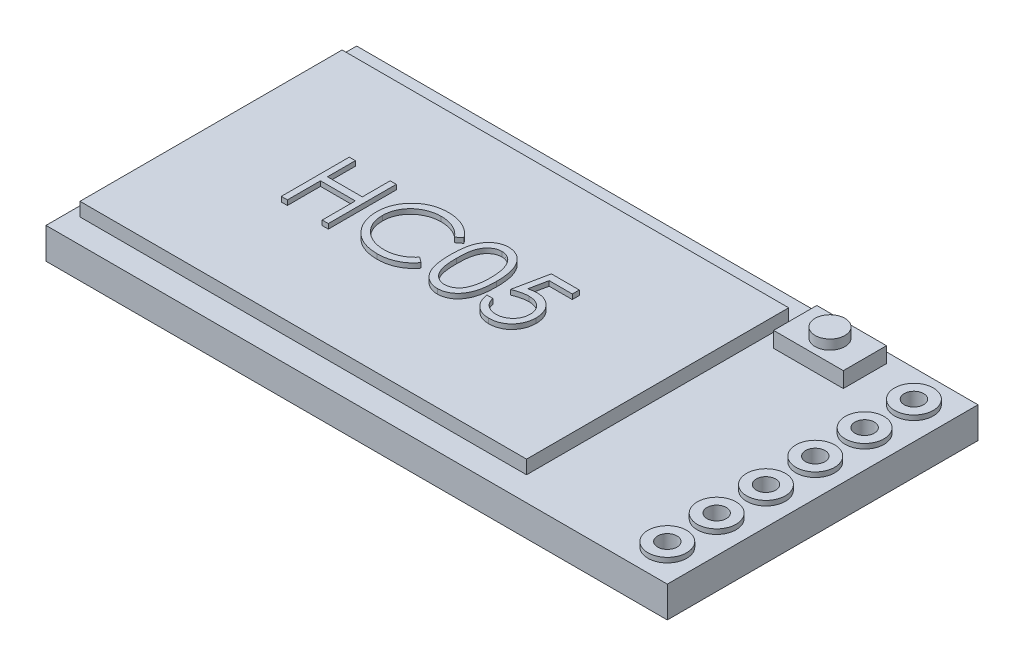
from build123d import *

# Parameters (mm, degrees)
SKETCH1_W           = 32
SKETCH1_H           = 16
SKETCH1_R           = 1
SKETCH1_W_2         = 23
SKETCH1_H_2         = 13.5
SKETCH1_W_3         = 3.590425902
SKETCH1_H_3         = 2.22474243
BOSS_EXTRUDE1_DEPTH = 1.6
SKETCH1_3_W         = 23
SKETCH1_3_H         = 13.5
BOSS_EXTRUDE2_DEPTH = 2.3
SKETCH1_4_W         = 3.590425902
SKETCH1_4_H         = 2.22474243
BOSS_EXTRUDE3_DEPTH = 2.4
SKETCH1_5_R         = 1
SKETCH1_5_R_2       = 0.5
BOSS_EXTRUDE4_DEPTH = 1.85
SKETCH2_R           = 0.766667283
BOSS_EXTRUDE5_DEPTH = 0.5
BOSS_EXTRUDE6_DEPTH = 0.25


with BuildPart() as part:
    # Sketch1 → Boss-Extrude1 (new body)
    with BuildSketch(Plane(origin=(0, 0, 0), x_dir=(1, 0, 0), z_dir=(0, 1, 0))):
        with Locations((16, 8)):
            Rectangle(SKETCH1_W, SKETCH1_H)
        with Locations((30.35, 1.65)):
            Circle(SKETCH1_R, mode=Mode.SUBTRACT)
        with Locations((30.35, 4.19)):
            Circle(SKETCH1_R, mode=Mode.SUBTRACT)
        with Locations((30.35, 6.73)):
            Circle(SKETCH1_R, mode=Mode.SUBTRACT)
        with Locations((12, 8)):
            Rectangle(SKETCH1_W_2, SKETCH1_H_2, mode=Mode.SUBTRACT)
        with Locations((30.35, 9.27)):
            Circle(SKETCH1_R, mode=Mode.SUBTRACT)
        with Locations((30.35, 11.81)):
            Circle(SKETCH1_R, mode=Mode.SUBTRACT)
        with Locations((26.014787049, 14.365507126)):
            Rectangle(SKETCH1_W_3, SKETCH1_H_3, mode=Mode.SUBTRACT)
        with Locations((30.35, 14.35)):
            Circle(SKETCH1_R, mode=Mode.SUBTRACT)
    extrude(amount=BOSS_EXTRUDE1_DEPTH)

    # Sketch1_3 → Boss-Extrude2 (add)
    with BuildSketch(Plane(origin=(0, 0, 0), x_dir=(1, 0, 0), z_dir=(0, 1, 0))):
        with Locations((12, 8)):
            Rectangle(SKETCH1_3_W, SKETCH1_3_H)
    extrude(amount=BOSS_EXTRUDE2_DEPTH)

    # Sketch1_4 → Boss-Extrude3 (add)
    with BuildSketch(Plane(origin=(0, 0, 0), x_dir=(1, 0, 0), z_dir=(0, 1, 0))):
        with Locations((26.014787049, 14.365507126)):
            Rectangle(SKETCH1_4_W, SKETCH1_4_H)
    extrude(amount=BOSS_EXTRUDE3_DEPTH)

    # Sketch1_5 → Boss-Extrude4 (add)
    # profile 1 of 6: a face of its own
    with BuildSketch(Plane(origin=(0, 0, 0), x_dir=(1, 0, 0), z_dir=(0, 1, 0))):
        with Locations((30.35, 14.35)):
            Circle(SKETCH1_5_R)
        with Locations((30.35, 14.35)):
            Circle(SKETCH1_5_R_2, mode=Mode.SUBTRACT)
    # profile 2 of 6: a face of its own
    with BuildSketch(Plane(origin=(0, 0, 0), x_dir=(1, 0, 0), z_dir=(0, 1, 0))):
        with Locations((30.35, 11.81)):
            Circle(SKETCH1_5_R)
        with Locations((30.35, 11.81)):
            Circle(SKETCH1_5_R_2, mode=Mode.SUBTRACT)
    # profile 3 of 6: a face of its own
    with BuildSketch(Plane(origin=(0, 0, 0), x_dir=(1, 0, 0), z_dir=(0, 1, 0))):
        with Locations((30.35, 9.27)):
            Circle(SKETCH1_5_R)
        with Locations((30.35, 9.27)):
            Circle(SKETCH1_5_R_2, mode=Mode.SUBTRACT)
    # profile 4 of 6: a face of its own
    with BuildSketch(Plane(origin=(0, 0, 0), x_dir=(1, 0, 0), z_dir=(0, 1, 0))):
        with Locations((30.35, 6.73)):
            Circle(SKETCH1_5_R)
        with Locations((30.35, 6.73)):
            Circle(SKETCH1_5_R_2, mode=Mode.SUBTRACT)
    # profile 5 of 6: a face of its own
    with BuildSketch(Plane(origin=(0, 0, 0), x_dir=(1, 0, 0), z_dir=(0, 1, 0))):
        with Locations((30.35, 4.19)):
            Circle(SKETCH1_5_R)
        with Locations((30.35, 4.19)):
            Circle(SKETCH1_5_R_2, mode=Mode.SUBTRACT)
    # profile 6 of 6: a face of its own
    with BuildSketch(Plane(origin=(0, 0, 0), x_dir=(1, 0, 0), z_dir=(0, 1, 0))):
        with Locations((30.35, 1.65)):
            Circle(SKETCH1_5_R)
        with Locations((30.35, 1.65)):
            Circle(SKETCH1_5_R_2, mode=Mode.SUBTRACT)
    extrude(amount=BOSS_EXTRUDE4_DEPTH)

    # Sketch2 → Boss-Extrude5 (add)
    with BuildSketch(Plane(origin=(0, 2.4, 0), x_dir=(1, 0, 0), z_dir=(0, 1, 0))):
        with Locations((26.015753043, 14.363135911)):
            Circle(SKETCH2_R)
    extrude(amount=BOSS_EXTRUDE5_DEPTH)

    # Sketch3 → Boss-Extrude6 (add)
    # profile 1 of 4: a face of its own
    with BuildSketch(Plane(origin=(0, 2.3, 0), x_dir=(1, 0, 0), z_dir=(0, 1, 0))):
        Polygon((5.71520575, 9.902396935), (6.029308314, 9.902396935), (6.029308314, 8.466499499), (7.824180109, 8.466499499), (7.824180109, 9.902396935), (8.138282673, 9.902396935), (8.138282673, 6.402396935), (7.824180109, 6.402396935), (7.824180109, 8.10752514), (6.029308314, 8.10752514), (6.029308314, 6.402396935), (5.71520575, 6.402396935), align=None)
    # profile 2 of 4: a face of its own
    with BuildSketch(Plane(origin=(0, 2.3, 0), x_dir=(1, 0, 0), z_dir=(0, 1, 0))):
        with BuildLine():
            Line((12.266487801, 9.260169371), (11.991648058, 9.049832832))
            add(Edge.make_bspline(
                [(11.991648058, 9.049832832), (11.972042169, 9.073198802), (11.933094723, 9.119615718), (11.87043552, 9.184795263), (11.805133877, 9.245860524), (11.737214756, 9.303102404), (11.665455637, 9.354519169), (11.591594838, 9.402790272), (11.514396793, 9.44605801), (11.407645058, 9.498520996), (11.26799721, 9.553267151), (11.092202371, 9.599170383), (10.908691272, 9.628391558), (10.783493673, 9.6315564), (10.719813122, 9.633166166)],
                knots=[0, 0, 0, 0, 0.757959112, 1.505699292, 2.245454638, 2.979532153, 3.711538275, 4.438200793, 5.171680507, 5.909471876, 7.393775596, 8.890124382, 10.418191784, 12, 12, 12, 12], degree=3))
            add(Edge.make_bspline(
                [(10.719813122, 9.633166166), (10.684729823, 9.632762203), (10.61488883, 9.631958027), (10.511240357, 9.621348902), (10.409527305, 9.606437692), (10.309815839, 9.584312369), (10.212232881, 9.55633975), (10.116140479, 9.522914336), (10.022929879, 9.481559496), (9.931311641, 9.435851236), (9.84353243, 9.384223791), (9.760477382, 9.32791044), (9.682449414, 9.267541343), (9.609386802, 9.202890237), (9.541214853, 9.134248276), (9.478427543, 9.060883935), (9.421242132, 8.983031761), (9.368525107, 8.901718354), (9.321312374, 8.817180562), (9.281782495, 8.729105492), (9.246777372, 8.639001388), (9.21907813, 8.545850228), (9.197153613, 8.450307462), (9.18202595, 8.352116674), (9.171537478, 8.251482994), (9.170737301, 8.183273682), (9.170333955, 8.148891326)],
                knots=[0, 0, 0, 0, 1.054917814, 2.100044995, 3.131103042, 4.146048494, 5.169673617, 6.183595914, 7.203665975, 8.234915748, 9.262203917, 10.264457458, 11.251630812, 12.227803204, 13.197192746, 14.159520551, 15.12972552, 16.100847026, 17.073214652, 18.039054194, 19.002613845, 19.979014051, 20.95965708, 21.949030935, 22.966165397, 24, 24, 24, 24], degree=3))
            add(Edge.make_bspline(
                [(9.170333955, 8.148891326), (9.171595774, 8.097160006), (9.174073189, 7.995592421), (9.196121523, 7.846821811), (9.229626614, 7.704301137), (9.279842191, 7.568921295), (9.341761241, 7.439012937), (9.420001853, 7.316774083), (9.51061839, 7.200357519), (9.61489281, 7.092514571), (9.729298626, 6.994000846), (9.852046537, 6.907250264), (9.982830825, 6.834935382), (10.120207455, 6.774759435), (10.265233569, 6.728502708), (10.417648372, 6.695938584), (10.577120367, 6.674696403), (10.686089767, 6.672662715), (10.741547898, 6.671627704)],
                knots=[0, 0, 0, 0, 1.029171465, 2.020641659, 2.987623507, 3.938342917, 4.889210282, 5.84687017, 6.821220943, 7.821438502, 8.827599549, 9.822697543, 10.807740252, 11.797342354, 12.80366471, 13.83203677, 14.896651826, 16, 16, 16, 16], degree=3))
            add(Edge.make_bspline(
                [(10.741547898, 6.671627704), (10.802650587, 6.673316484), (10.922915295, 6.676640407), (11.099283322, 6.704799656), (11.268119087, 6.750457574), (11.429431674, 6.814355496), (11.58276632, 6.897420784), (11.728362981, 6.998118661), (11.866344551, 7.117406994), (11.949315833, 7.208490122), (11.991648058, 7.254961038)],
                knots=[0, 0, 0, 0, 1.028121516, 2.023589091, 2.998037872, 3.967518031, 4.937445131, 5.927275754, 6.942489185, 8, 8, 8, 8], degree=3))
            Line((11.991648058, 7.254961038), (12.266487801, 7.046727865))
            add(Edge.make_bspline(
                [(12.266487801, 7.046727865), (12.244369692, 7.018189413), (12.200239416, 6.961249206), (12.128781399, 6.880977497), (12.053504102, 6.805473461), (11.973848392, 6.73534584), (11.8907306, 6.669191374), (11.802658288, 6.608889543), (11.710789255, 6.553598659), (11.615434777, 6.502971734), (11.516696164, 6.458054487), (11.414691729, 6.419600719), (11.309861153, 6.38647583), (11.202199645, 6.359223893), (11.091483888, 6.337952809), (10.978113414, 6.323733134), (10.861843539, 6.31399122), (10.783402118, 6.313103304), (10.743651263, 6.312653345)],
                knots=[0, 0, 0, 0, 0.986787822, 1.968848986, 2.935600012, 3.899624008, 4.868462664, 5.837806735, 6.815139263, 7.798259679, 8.787526145, 9.778297419, 10.776456485, 11.791383307, 12.812564526, 13.85620153, 14.913611965, 16, 16, 16, 16], degree=3))
            add(Edge.make_bspline(
                [(10.743651263, 6.312653345), (10.706007596, 6.312915338), (10.631571906, 6.313433396), (10.521673154, 6.321825563), (10.414683573, 6.3332753), (10.310908948, 6.350515431), (10.209782972, 6.370859771), (10.112222388, 6.398131028), (10.017267178, 6.428680194), (9.925298837, 6.464585181), (9.836239137, 6.505101364), (9.750375326, 6.550892923), (9.667746893, 6.601574787), (9.587541473, 6.656029798), (9.510943889, 6.7160071), (9.437290363, 6.780673734), (9.366167887, 6.849811745), (9.322165202, 6.899666598), (9.300041487, 6.924732672)],
                knots=[0, 0, 0, 0, 1.114604814, 2.203992996, 3.262667896, 4.300477797, 5.318619304, 6.316056647, 7.298880507, 8.271930387, 9.238335007, 10.195173496, 11.151986948, 12.108099108, 13.064862484, 14.031167946, 15.010108607, 16, 16, 16, 16], degree=3))
            add(Edge.make_bspline(
                [(9.300041487, 6.924732672), (9.264605844, 6.968273861), (9.194162367, 7.054830572), (9.104036683, 7.195116553), (9.026889128, 7.341584762), (8.964513207, 7.49500469), (8.915750474, 7.655032078), (8.881969279, 7.821747592), (8.860017675, 7.994995534), (8.857507386, 8.112832323), (8.856231391, 8.172729467)],
                knots=[0, 0, 0, 0, 0.994628077, 1.977248131, 2.950237994, 3.925870899, 4.908910175, 5.911660606, 6.938484602, 8, 8, 8, 8], degree=3))
            add(Edge.make_bspline(
                [(8.856231391, 8.172729467), (8.857786585, 8.235684921), (8.860846331, 8.359545845), (8.886842126, 8.541319799), (8.928660923, 8.715471197), (8.988057811, 8.881674942), (9.063363163, 9.040805222), (9.156389776, 9.191646427), (9.266056919, 9.335163227), (9.391504486, 9.469177978), (9.529071822, 9.591717331), (9.676390635, 9.699523534), (9.833172582, 9.78924105), (9.997690434, 9.864237213), (10.171176116, 9.921881676), (10.353259485, 9.962234863), (10.5435984, 9.987351979), (10.673460825, 9.990527187), (10.739444532, 9.992140525)],
                knots=[0, 0, 0, 0, 1.032925535, 2.032216505, 3.007276963, 3.968222605, 4.92396291, 5.891752235, 6.871517503, 7.883894988, 8.900124299, 9.891468569, 10.874487609, 11.85992873, 12.854644235, 13.869047385, 14.917252991, 16, 16, 16, 16], degree=3))
            add(Edge.make_bspline(
                [(10.739444532, 9.992140525), (10.779659004, 9.991658387), (10.859259501, 9.990704043), (10.977012154, 9.981397901), (11.091654481, 9.965884294), (11.203265463, 9.944768224), (11.312388079, 9.918560903), (11.41818832, 9.884420605), (11.521287007, 9.845384073), (11.621033915, 9.800425607), (11.716950465, 9.749958866), (11.809006784, 9.694543242), (11.896471642, 9.634247437), (11.979960491, 9.569584262), (12.058076702, 9.499185702), (12.13303818, 9.424988106), (12.202299259, 9.344854282), (12.245052454, 9.288449348), (12.266487801, 9.260169371)],
                knots=[0, 0, 0, 0, 1.096760587, 2.17092713, 3.219439832, 4.250915756, 5.268269357, 6.278326846, 7.281116186, 8.274029601, 9.260640565, 10.235837813, 11.203064059, 12.156899882, 13.114053108, 14.069676657, 15.032185724, 16, 16, 16, 16], degree=3))
        make_face()
    # profile 3 of 4: a face of its own
    with BuildSketch(Plane(origin=(0, 2.3, 0), x_dir=(1, 0, 0), z_dir=(0, 1, 0))):
        with BuildLine():
            add(Edge.make_bspline(
                [(12.670333955, 8.150994691), (12.670661973, 8.207092079), (12.671299153, 8.316062063), (12.678387574, 8.474846706), (12.690162917, 8.623806995), (12.70630029, 8.762950061), (12.72593827, 8.892311825), (12.752153756, 9.011546582), (12.781966559, 9.121206189), (12.816519005, 9.221648237), (12.855506794, 9.31422594), (12.897941055, 9.400651142), (12.945505849, 9.480793074), (12.995482762, 9.555930864), (13.049894833, 9.624834559), (13.107193624, 9.688477222), (13.1696155, 9.745387972), (13.235038509, 9.797234275), (13.304054973, 9.842683746), (13.374697639, 9.882716485), (13.447452745, 9.916916352), (13.522518928, 9.943806788), (13.599221486, 9.966017635), (13.677828552, 9.981206582), (13.758469916, 9.990763491), (13.812901351, 9.991677159), (13.840506231, 9.992140525)],
                knots=[0, 0, 0, 0, 1.646270934, 3.197905019, 4.663502075, 6.030701355, 7.308322542, 8.50163776, 9.611534131, 10.641858119, 11.616356847, 12.558055219, 13.465016945, 14.349605745, 15.204443733, 16.039544428, 16.859896111, 17.680448484, 18.487036065, 19.28249412, 20.06191084, 20.843045899, 21.620316918, 22.403196591, 23.190181807, 24, 24, 24, 24], degree=3))
            add(Edge.make_bspline(
                [(13.840506231, 9.992140525), (13.868341709, 9.99165271), (13.923697718, 9.990682599), (14.005538094, 9.981358656), (14.085487775, 9.965887533), (14.163205914, 9.943966559), (14.2393309, 9.916770882), (14.313267308, 9.882683765), (14.38547439, 9.843004897), (14.454804677, 9.79638102), (14.522019293, 9.744398744), (14.585467256, 9.685636075), (14.645154341, 9.620686356), (14.701829647, 9.550244492), (14.753885244, 9.472959407), (14.803458676, 9.390175297), (14.847830712, 9.300444432), (14.890565387, 9.205263965), (14.927452374, 9.102000306), (14.960718619, 8.991235545), (14.987597588, 8.871661358), (15.00998686, 8.743905113), (15.027331756, 8.60749763), (15.039964398, 8.462731314), (15.046637483, 8.309510924), (15.047894185, 8.204753075), (15.048539083, 8.150994691)],
                knots=[0, 0, 0, 0, 0.810914788, 1.612654377, 2.396697861, 3.181598691, 3.963628158, 4.749916497, 5.551656086, 6.361998678, 7.18212741, 8.025565596, 8.878627764, 9.750805457, 10.657531673, 11.591944965, 12.560506719, 13.57287815, 14.630710178, 15.753379473, 16.941251878, 18.199788006, 19.531962791, 20.947069417, 22.433333509, 24, 24, 24, 24], degree=3))
            add(Edge.make_bspline(
                [(15.048539083, 8.150994691), (15.047887499, 8.097470784), (15.046617913, 7.993181632), (15.040039206, 7.840650656), (15.027080575, 7.696652613), (15.010870587, 7.560842151), (14.988419624, 7.433784532), (14.960814458, 7.315040083), (14.930164135, 7.204096012), (14.892329341, 7.1018612), (14.85091863, 7.006909477), (14.805863434, 6.918242329), (14.757593608, 6.835076036), (14.705004863, 6.758076289), (14.64895145, 6.686697632), (14.588233661, 6.622200009), (14.524563076, 6.563029338), (14.45715066, 6.51037771), (14.386739109, 6.464292905), (14.314780032, 6.423079055), (14.239996649, 6.38984636), (14.164083696, 6.361311319), (14.08595533, 6.339510867), (14.005708939, 6.324437012), (13.923752703, 6.313865163), (13.868351138, 6.313058683), (13.840506231, 6.312653345)],
                knots=[0, 0, 0, 0, 1.561518951, 3.042555995, 4.452378317, 5.7783523, 7.031515105, 8.214008947, 9.334062868, 10.386615937, 11.391082383, 12.354592575, 13.286541444, 14.194233754, 15.072674879, 15.931287219, 16.775624067, 17.606195743, 18.42308326, 19.229000347, 20.022332153, 20.807536673, 21.593273796, 22.3848459, 23.188221202, 24, 24, 24, 24], degree=3))
            add(Edge.make_bspline(
                [(13.840506231, 6.312653345), (13.812902117, 6.313119701), (13.758472192, 6.314039263), (13.677819767, 6.323552994), (13.599537323, 6.338848497), (13.523238569, 6.360265102), (13.448532054, 6.386479938), (13.376435768, 6.420633621), (13.306148084, 6.45996769), (13.237856528, 6.504763112), (13.172844367, 6.556084795), (13.110745761, 6.612849084), (13.053120742, 6.676472495), (12.999486647, 6.745950418), (12.948512559, 6.82064366), (12.901623185, 6.901572033), (12.858252331, 6.988414644), (12.81860884, 7.081732555), (12.783460177, 7.182887482), (12.752412469, 7.293036661), (12.727898311, 7.413152297), (12.706915356, 7.542269664), (12.689990973, 7.680943595), (12.678436648, 7.829249373), (12.671295333, 7.987094582), (12.670660262, 8.095364356), (12.670333955, 8.150994691)],
                knots=[0, 0, 0, 0, 0.810891512, 1.598919785, 2.382837074, 3.152667961, 3.926044502, 4.706494248, 5.493654104, 6.291793342, 7.103789334, 7.925228297, 8.761435821, 9.622817696, 10.50288917, 11.416980706, 12.369136599, 13.353924996, 14.394355917, 15.514179734, 16.714354668, 17.994756427, 19.357759367, 20.818452758, 22.365282078, 24, 24, 24, 24], degree=3))
        make_face()
        with BuildLine():
            add(Edge.make_bspline(
                [(12.984436519, 8.152396935), (12.984555966, 8.105648236), (12.98478779, 8.014918191), (12.99084399, 7.88307493), (12.999094222, 7.760104602), (13.00973552, 7.645851065), (13.025538468, 7.540701053), (13.043245256, 7.44393137), (13.064793345, 7.356054133), (13.090288363, 7.276466322), (13.11932746, 7.203817253), (13.151033324, 7.136216038), (13.185094047, 7.072864102), (13.223213197, 7.014330493), (13.264728261, 6.960424329), (13.30870152, 6.910191497), (13.356774104, 6.865394516), (13.423277847, 6.811667661), (13.511074321, 6.756148527), (13.621694776, 6.707802437), (13.735363227, 6.677419981), (13.812514477, 6.673556225), (13.851023058, 6.671627704)],
                knots=[0, 0, 0, 0, 1.459021318, 2.831673884, 4.118529203, 5.306027144, 6.411944654, 7.436330062, 8.375795394, 9.233974572, 10.042671642, 10.816086306, 11.563610507, 12.285937304, 12.993564865, 13.685989202, 14.367179055, 15.041617293, 16.353048772, 17.594441528, 18.799311195, 20, 20, 20, 20], degree=3))
            add(Edge.make_bspline(
                [(13.851023058, 6.671627704), (13.889780729, 6.673225485), (13.967216053, 6.676417748), (14.080349848, 6.707216485), (14.190180118, 6.753686025), (14.276252058, 6.80863353), (14.341734602, 6.86096186), (14.388651592, 6.905576508), (14.43171364, 6.955532375), (14.472555715, 7.009431671), (14.510014791, 7.068304155), (14.544077928, 7.131866731), (14.575161276, 7.200295908), (14.592870322, 7.248065648), (14.6019245, 7.272489082)],
                knots=[0, 0, 0, 0, 1.353760809, 2.704726607, 4.075137775, 5.516104923, 6.260822281, 7.007110065, 7.778089737, 8.566572457, 9.372053459, 10.217411131, 11.088608312, 12, 12, 12, 12], degree=3))
            add(Edge.make_bspline(
                [(14.6019245, 7.272489082), (14.612476268, 7.303718822), (14.633900882, 7.367128586), (14.661512656, 7.465492238), (14.683258055, 7.568695002), (14.702821421, 7.676120119), (14.716174477, 7.78855982), (14.72692229, 7.905666204), (14.733252977, 8.027527566), (14.734037728, 8.110322557), (14.734436519, 8.152396935)],
                knots=[0, 0, 0, 0, 0.884706709, 1.796334032, 2.740027952, 3.714592787, 4.726048262, 5.777819803, 6.87074269, 8, 8, 8, 8], degree=3))
            add(Edge.make_bspline(
                [(14.734436519, 8.152396935), (14.73388633, 8.194464508), (14.732810042, 8.276757672), (14.728696055, 8.397275853), (14.71807248, 8.511743614), (14.706273361, 8.620654087), (14.68887614, 8.723404389), (14.670118333, 8.820854695), (14.644917121, 8.911797719), (14.617997346, 8.997657301), (14.587186951, 9.077457956), (14.553271216, 9.151571742), (14.517049458, 9.220356467), (14.477707217, 9.283623408), (14.435711534, 9.341655951), (14.389953985, 9.393290546), (14.342249612, 9.440127514), (14.275432426, 9.493590083), (14.187958136, 9.548101778), (14.079112489, 9.598267538), (13.965841845, 9.627075831), (13.889268391, 9.631137518), (13.851023058, 9.633166166)],
                knots=[0, 0, 0, 0, 1.31362396, 2.569729283, 3.763502607, 4.902122613, 5.988968491, 7.01645872, 7.998833611, 8.933434873, 9.825090667, 10.667526885, 11.477055099, 12.250526234, 12.991942729, 13.710640831, 14.402115721, 15.076753259, 16.378508321, 17.609869233, 18.806226677, 20, 20, 20, 20], degree=3))
            add(Edge.make_bspline(
                [(13.851023058, 9.633166166), (13.812312466, 9.631134719), (13.73482076, 9.627068125), (13.620372805, 9.598374871), (13.510668454, 9.548361906), (13.423425479, 9.493409533), (13.356561693, 9.441071222), (13.309478999, 9.395684768), (13.265332827, 9.346038513), (13.224665127, 9.291636598), (13.186575844, 9.233171231), (13.151594831, 9.170182466), (13.120077501, 9.102351102), (13.090992965, 9.029734667), (13.065420177, 8.950153722), (13.044326214, 8.862384729), (13.024839161, 8.765922837), (13.011043892, 8.660203329), (12.998780136, 8.545921176), (12.990898788, 8.422643857), (12.984767531, 8.290579477), (12.984549066, 8.199380318), (12.984436519, 8.152396935)],
                knots=[0, 0, 0, 0, 1.207732386, 2.417664972, 3.655092373, 4.956220595, 5.625982001, 6.301752483, 6.994047911, 7.697131622, 8.419323945, 9.170223765, 9.943494443, 10.752040957, 11.610060368, 12.549350801, 13.567764191, 14.679664412, 15.874934091, 17.154273443, 18.533957287, 20, 20, 20, 20], degree=3))
        make_face(mode=Mode.SUBTRACT)
    # profile 4 of 4: a face of its own
    with BuildSketch(Plane(origin=(0, 2.3, 0), x_dir=(1, 0, 0), z_dir=(0, 1, 0))):
        with BuildLine():
            Line((17.561359596, 9.902396935), (17.561359596, 9.543422576))
            Line((17.561359596, 9.543422576), (16.370854789, 9.543422576))
            Line((16.370854789, 9.543422576), (16.182253026, 8.622849659))
            add(Edge.make_bspline(
                [(16.182253026, 8.622849659), (16.2193089, 8.633079931), (16.291098796, 8.652899465), (16.397058657, 8.674905235), (16.49765086, 8.688170679), (16.562926231, 8.68998199), (16.594512641, 8.690858474)],
                knots=[0, 0, 0, 0, 1.100273476, 2.13160584, 3.095893838, 4, 4, 4, 4], degree=3))
            add(Edge.make_bspline(
                [(16.594512641, 8.690858474), (16.633596381, 8.690012538), (16.710444778, 8.688349217), (16.822883725, 8.672377367), (16.930216618, 8.647237453), (17.032218989, 8.612116931), (17.129079539, 8.567207198), (17.219907101, 8.511107258), (17.306065014, 8.445573926), (17.386007608, 8.370228914), (17.458531916, 8.287307298), (17.522297905, 8.198149427), (17.576460496, 8.103621764), (17.620021251, 8.002821156), (17.654805585, 7.896862002), (17.67795758, 7.78462942), (17.693374289, 7.6671813), (17.695096675, 7.58687673), (17.695974981, 7.545926582)],
                knots=[0, 0, 0, 0, 1.052922333, 2.070308379, 3.05430497, 4.020497103, 4.973039431, 5.925935799, 6.892292201, 7.88610001, 8.88166317, 9.857072816, 10.836096531, 11.812156883, 12.81219415, 13.836441305, 14.89672472, 16, 16, 16, 16], degree=3))
            add(Edge.make_bspline(
                [(17.695974981, 7.545926582), (17.695309906, 7.517404362), (17.693988743, 7.460745375), (17.687270155, 7.376601174), (17.674334439, 7.294238341), (17.656966715, 7.213645949), (17.634424297, 7.134976577), (17.607135243, 7.058005049), (17.573739216, 6.983210442), (17.537107841, 6.909885047), (17.495861363, 6.83968654), (17.450082855, 6.774037553), (17.401717364, 6.711953272), (17.349675978, 6.654099539), (17.293474983, 6.600856521), (17.233795017, 6.551908239), (17.171112297, 6.506426909), (17.104457055, 6.466258714), (17.035314572, 6.429295758), (16.962686355, 6.39897222), (16.888225655, 6.371861692), (16.810860779, 6.350252165), (16.730766966, 6.33331961), (16.647812191, 6.32181901), (16.562431521, 6.313442572), (16.504556508, 6.312918215), (16.475321936, 6.312653345)],
                knots=[0, 0, 0, 0, 1.056347294, 2.098418968, 3.122841568, 4.141288669, 5.149314143, 6.15115421, 7.162517403, 8.180376062, 9.185164535, 10.17417709, 11.141909838, 12.097768115, 13.052685741, 14.0056014, 14.954263652, 15.917497458, 16.885230207, 17.854509472, 18.828990115, 19.81800267, 20.826176721, 21.857883937, 22.917946725, 24, 24, 24, 24], degree=3))
            add(Edge.make_bspline(
                [(16.475321936, 6.312653345), (16.440447755, 6.313344183), (16.371836925, 6.314703325), (16.271316358, 6.328921811), (16.174601752, 6.349285727), (16.082471651, 6.379921997), (15.994100387, 6.418309292), (15.910677669, 6.466825463), (15.830071893, 6.521804567), (15.755559856, 6.58668492), (15.686403743, 6.657600602), (15.624497234, 6.734558243), (15.569363657, 6.816287685), (15.52188591, 6.903185839), (15.481387889, 6.99502437), (15.449572901, 7.092147371), (15.423894546, 7.194047375), (15.413031125, 7.264200885), (15.407513442, 7.299832832)],
                knots=[0, 0, 0, 0, 1.0467383, 2.05933395, 3.04377827, 4.011590433, 4.970194871, 5.932262533, 6.905835911, 7.896367577, 8.894135286, 9.877477877, 10.858688626, 11.851381753, 12.8477658, 13.868841284, 14.917554742, 16, 16, 16, 16], degree=3))
            Line((15.407513442, 7.299832832), (15.721616007, 7.299832832))
            add(Edge.make_bspline(
                [(15.721616007, 7.299832832), (15.729344564, 7.26645638), (15.74419928, 7.202304985), (15.776805029, 7.112173644), (15.816670905, 7.03185442), (15.864075253, 6.960284837), (15.920625284, 6.89787584), (15.985154712, 6.842258778), (16.057502436, 6.792083648), (16.137895665, 6.750260881), (16.222708744, 6.714592128), (16.311475954, 6.690840433), (16.401780301, 6.67413954), (16.462858671, 6.672467779), (16.493551103, 6.671627704)],
                knots=[0, 0, 0, 0, 1.136247022, 2.183929868, 3.172523383, 4.106158343, 5.02341133, 5.958108904, 6.928429099, 7.938127109, 8.96079061, 9.975095812, 10.982467395, 12, 12, 12, 12], degree=3))
            add(Edge.make_bspline(
                [(16.493551103, 6.671627704), (16.523509547, 6.672448482), (16.582497969, 6.674064601), (16.669309356, 6.686503613), (16.75312223, 6.705661184), (16.833109587, 6.734331039), (16.910671127, 6.769175757), (16.983844897, 6.813890833), (17.054747774, 6.865350852), (17.121175908, 6.924307482), (17.182015357, 6.989277176), (17.235771478, 7.05875457), (17.280548391, 7.132871416), (17.3182825, 7.210344569), (17.346935799, 7.292023126), (17.36737678, 7.377524302), (17.379379839, 7.467059282), (17.381031019, 7.528128591), (17.381872417, 7.559247897)],
                knots=[0, 0, 0, 0, 1.027316725, 2.022795036, 3.002884548, 3.971462791, 4.93288096, 5.914575861, 6.907176829, 7.935150275, 8.956128384, 9.956726525, 10.942570165, 11.921478529, 12.907843606, 13.90538589, 14.932640048, 16, 16, 16, 16], degree=3))
            add(Edge.make_bspline(
                [(17.381872417, 7.559247897), (17.381213937, 7.587323648), (17.379925057, 7.642277937), (17.369394487, 7.722677144), (17.351077515, 7.798750186), (17.325653635, 7.87086442), (17.293374127, 7.939087862), (17.253927815, 8.003490923), (17.206574417, 8.063224756), (17.152482528, 8.118317309), (17.093224487, 8.169162184), (17.027780745, 8.212506271), (16.957520818, 8.248970188), (16.883291218, 8.280438187), (16.80332632, 8.303038932), (16.719209688, 8.320006818), (16.63003298, 8.32982218), (16.569062291, 8.331184069), (16.537721776, 8.331884115)],
                knots=[0, 0, 0, 0, 1.045622112, 2.046656509, 3.013763289, 3.955457236, 4.890082067, 5.820317437, 6.762574623, 7.722996705, 8.69280354, 9.665887285, 10.63943826, 11.638615906, 12.663482002, 13.728887084, 14.832589034, 16, 16, 16, 16], degree=3))
            add(Edge.make_bspline(
                [(16.537721776, 8.331884115), (16.510592847, 8.331303523), (16.454578492, 8.33010475), (16.368655665, 8.321278253), (16.278363942, 8.307038959), (16.184049446, 8.287452711), (16.085428938, 8.261821634), (15.982710538, 8.231107134), (15.875678271, 8.194385135), (15.803560547, 8.166652921), (15.766487801, 8.152396935)],
                knots=[0, 0, 0, 0, 0.817624296, 1.688186739, 2.600797293, 3.572016777, 4.590301741, 5.671205678, 6.80286297, 8, 8, 8, 8], degree=3))
            Line((15.766487801, 8.152396935), (16.12546216, 9.902396935))
            Line((16.12546216, 9.902396935), (17.561359596, 9.902396935))
        make_face()
    extrude(amount=BOSS_EXTRUDE6_DEPTH)


solid = part.part
